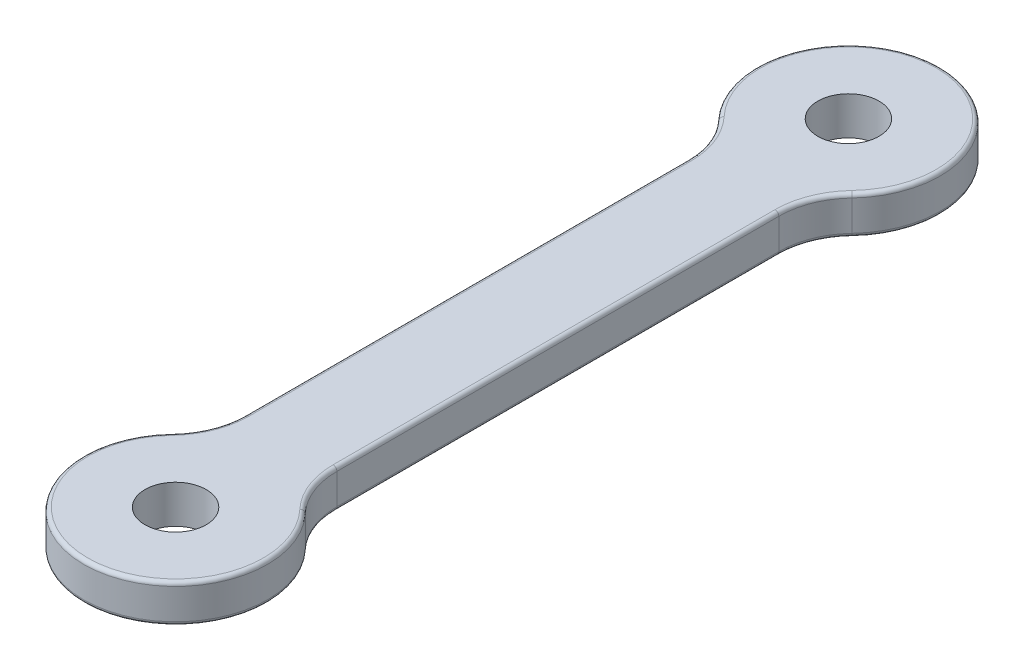
from build123d import *

# Parameters (mm, degrees)
SKETCH1_R           = 2
BOSS_EXTRUDE1_DEPTH = 2.5
FILLET1_R           = 5
FILLET2_R           = 0.25


with BuildPart() as part:
    # Sketch1 → Boss-Extrude1 (new body)
    with BuildSketch(Plane(origin=(0, 0, 0), x_dir=(1, 0, 0), z_dir=(0, 1, 0))):
        with BuildLine():
            ThreePointArc((-3, -16.803847577), (0, -28), (3, -16.803847577))
            Line((3, -16.803847577), (3, 16.803847577))
            ThreePointArc((3, 16.803847577), (0, 28), (-3, 16.803847577))
            Line((-3, 16.803847577), (-3, -16.803847577))
        make_face()
        with Locations((0, -22)):
            Circle(SKETCH1_R, mode=Mode.SUBTRACT)
        with Locations((0, 22)):
            Circle(SKETCH1_R, mode=Mode.SUBTRACT)
    extrude(amount=BOSS_EXTRUDE1_DEPTH)

    # Fillet1
    fillet1_edges = [part.edges().sort_by_distance(p)[0] for p in [
        (-3, 1.25, 16.803847577),
        (-3, 1.25, -16.803847577),
        (3, 1.25, -16.803847577),
        (3, 1.25, 16.803847577),
    ]]
    fillet(fillet1_edges, radius=FILLET1_R)

    # Fillet2
    fillet2_edges = [part.edges().sort_by_distance(p)[0] for p in [
        (0, 0, -28),
        (0, 2.5, -28),
        (3, 0, 0),
        (3, 2.5, 0),
        (0, 0, 28),
        (0, 2.5, 28),
        (-3, 0, 0),
        (-3, 2.5, 0),
        (3.353398114, 0, -16.296537929),
        (3.353398114, 2.5, -16.296537929),
        (3.353398114, 0, 16.296537929),
        (3.353398114, 2.5, 16.296537929),
        (-3.353398114, 0, 16.296537929),
        (-3.353398114, 2.5, 16.296537929),
        (-3.353398114, 0, -16.296537929),
        (-3.353398114, 2.5, -16.296537929),
    ]]
    fillet(fillet2_edges, radius=FILLET2_R)


solid = part.part
